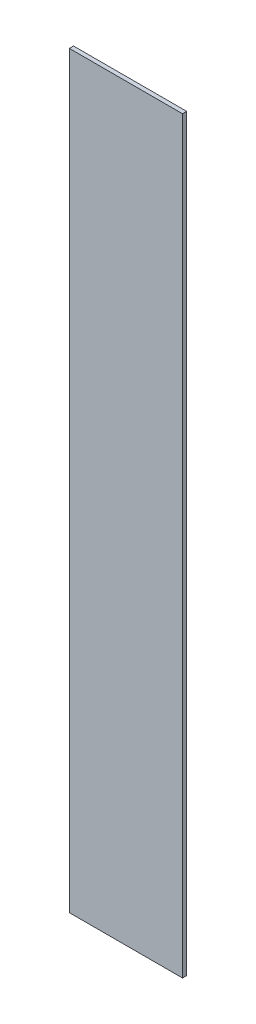
from build123d import *

# Parameters (mm, degrees)
SKETCH1_W           = 86.36
SKETCH1_H           = 571.5
BOSS_EXTRUDE1_DEPTH = 3.175


with BuildPart() as part:
    # Sketch1 → Boss-Extrude1 (new body)
    with BuildSketch(Plane.XY):
        with Locations((43.18, 285.75)):
            Rectangle(SKETCH1_W, SKETCH1_H)
    extrude(amount=BOSS_EXTRUDE1_DEPTH)


solid = part.part
